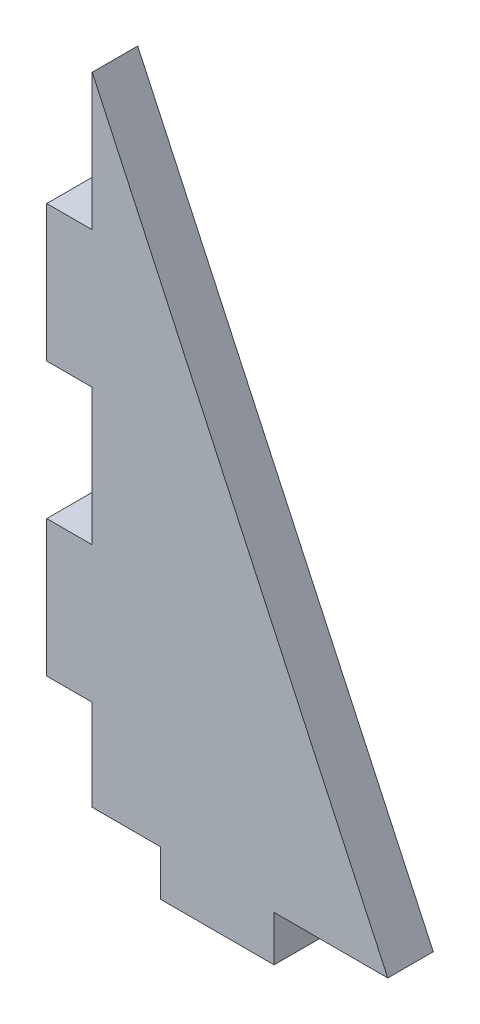
from build123d import *

# Parameters (mm, degrees)
BOSS_EXTRUDE1_DEPTH = 5.08
SKETCH2_W           = 5.08
SKETCH2_H           = 15.24
SKETCH2_H_2         = 10.16
SKETCH2_H_3         = 5.08
SKETCH2_W_2         = 7.62
SKETCH2_W_3         = 12.7
CUT_EXTRUDE1_DEPTH  = 5.08


with BuildPart() as part:
    # Sketch1 → Boss-Extrude1 (new body)
    with BuildSketch(Plane.XY):
        Polygon((0, 0), (0, 76.2), (5.08, 76.2), (38.1, 5.08), (38.1, 0), align=None)
    extrude(amount=BOSS_EXTRUDE1_DEPTH)

    # Sketch2 → Cut-Extrude1 (cut)
    with BuildSketch(Plane.XY.offset(5.08)):
        with Locations((2.54, 68.58)):
            Rectangle(SKETCH2_W, SKETCH2_H)
        with Locations((2.54, 38.1)):
            Rectangle(SKETCH2_W, SKETCH2_H)
        with Locations((2.54, 10.16)):
            Rectangle(SKETCH2_W, SKETCH2_H_2)
        with Locations((2.54, 2.54)):
            Rectangle(SKETCH2_W, SKETCH2_H_3)
        with Locations((8.89, 2.54)):
            Rectangle(SKETCH2_W_2, SKETCH2_H_3)
        with Locations((31.75, 2.54)):
            Rectangle(SKETCH2_W_3, SKETCH2_H_3)
    extrude(amount=-CUT_EXTRUDE1_DEPTH, mode=Mode.SUBTRACT)


solid = part.part
